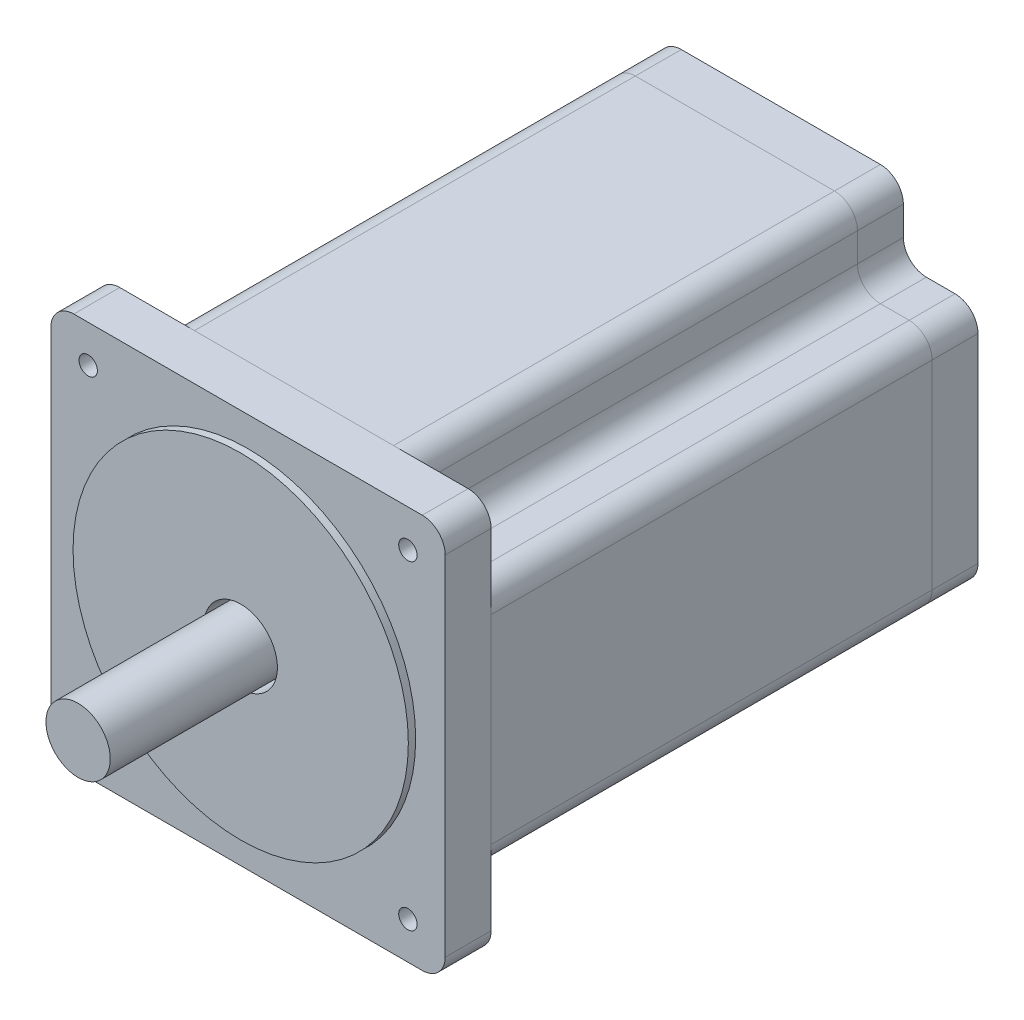
from build123d import *

# Parameters (mm, degrees)
SZKIC1_W                    = 85.85
SZKIC1_H                    = 85.85
DODANIE_WYCI_GNI_CIE2_DEPTH = 116
SZKIC3_R                    = 36.5
DODANIE_WYCI_GNI_CIE3_DEPTH = 1.6
SZKIC5_W                    = 16.25
SZKIC5_H                    = 16.25
WYTNIJ_WYCI_GNI_CIE1_DEPTH  = 106
SZYK_LINIOWY1_COUNT         = 2
SZYK_LINIOWY1_PITCH         = 69.6
SZYK_LINIOWY1_COUNT_DIR2    = 2
SZYK_LINIOWY1_PITCH_DIR2    = 69.6
SZKIC6_R                    = 2
WYTNIJ_WYCI_GNI_CIE2_DEPTH  = 10
SZYK_LINIOWY2_COUNT         = 2
SZYK_LINIOWY2_PITCH         = 69.6
SZYK_LINIOWY2_COUNT_DIR2    = 2
SZYK_LINIOWY2_PITCH_DIR2    = 69.6
SZKIC7_R                    = 7
DODANIE_WYCI_GNI_CIE4_DEPTH = 35.4
SZKIC8_R                    = 8
SZKIC8_R_2                  = 7
WYTNIJ_WYCI_GNI_CIE5_DEPTH  = 10
ZAOKR_GLENIE1_R             = 5
ZAOKR_GLENIE2_R             = 5
ZAOKR_GLENIE3_R             = 5


with BuildPart() as part:
    # Szkic1 → Dodanie-wyciągnięcie2 (new body)
    with BuildSketch(Plane.XY):
        Rectangle(SZKIC1_W, SZKIC1_H)
    extrude(amount=DODANIE_WYCI_GNI_CIE2_DEPTH)

    # Szkic3 → Dodanie-wyciągnięcie3 (add)
    with BuildSketch(Plane.XY.offset(116)):
        Circle(SZKIC3_R)
    extrude(amount=DODANIE_WYCI_GNI_CIE3_DEPTH)

    # Szkic5 → Wytnij-wyciągnięcie1 (cut)
    with BuildSketch(Plane(origin=(0, 0, 0), x_dir=(-1, 0, 0), z_dir=(0, 0, -1))):
        with Locations((-34.8, 34.8)):
            Rectangle(SZKIC5_W, SZKIC5_H)
    wytnij_wyci_gni_cie1 = extrude(amount=-WYTNIJ_WYCI_GNI_CIE1_DEPTH, mode=Mode.SUBTRACT)

    # Szyk liniowy1: Wytnij-wyci_gni_cie1 2 × 2
    with Locations(*[(-i * SZYK_LINIOWY1_PITCH, -j * SZYK_LINIOWY1_PITCH_DIR2, 0) for i in range(SZYK_LINIOWY1_COUNT) for j in range(SZYK_LINIOWY1_COUNT_DIR2) if (i, j) != (0, 0)]):
        add(wytnij_wyci_gni_cie1, mode=Mode.SUBTRACT)

    # Szkic6 → Wytnij-wyciągnięcie2 (cut)
    with BuildSketch(Plane.XY.offset(116)):
        with Locations((-34.8, 34.8)):
            Circle(SZKIC6_R)
    wytnij_wyci_gni_cie2 = extrude(amount=-WYTNIJ_WYCI_GNI_CIE2_DEPTH, mode=Mode.SUBTRACT)

    # Szyk liniowy2: Wytnij-wyci_gni_cie2 2 × 2
    with Locations(*[(i * SZYK_LINIOWY2_PITCH, -j * SZYK_LINIOWY2_PITCH_DIR2, 0) for i in range(SZYK_LINIOWY2_COUNT) for j in range(SZYK_LINIOWY2_COUNT_DIR2) if (i, j) != (0, 0)]):
        add(wytnij_wyci_gni_cie2, mode=Mode.SUBTRACT)

    # Szkic7 → Dodanie-wyciągnięcie4 (add)
    with BuildSketch(Plane.XY.offset(117.6)):
        Circle(SZKIC7_R)
    extrude(amount=DODANIE_WYCI_GNI_CIE4_DEPTH)

    # Szkic8 → Wytnij-wyciągnięcie5 (cut)
    with BuildSketch(Plane.XY.offset(117.6)):
        Circle(SZKIC8_R)
        Circle(SZKIC8_R_2, mode=Mode.SUBTRACT)
    extrude(amount=-WYTNIJ_WYCI_GNI_CIE5_DEPTH, mode=Mode.SUBTRACT)

    # Zaokrąglenie1
    zaokr_glenie1_edges = [part.edges().sort_by_distance(p)[0] for p in [
        (42.925, -42.925, 111),
        (-42.925, -42.925, 111),
        (-42.925, 42.925, 111),
        (42.925, 42.925, 111),
    ]]
    fillet(zaokr_glenie1_edges, radius=ZAOKR_GLENIE1_R)

    # Zaokrąglenie2
    zaokr_glenie2_edges = [part.edges().sort_by_distance(p)[0] for p in [
        (42.925, 26.675, 53),
        (26.675, 42.925, 53),
        (42.925, -26.675, 53),
        (26.675, -42.925, 53),
        (-26.675, 42.925, 53),
        (-42.925, 26.675, 53),
        (-26.675, -42.925, 53),
        (-42.925, -26.675, 53),
    ]]
    fillet(zaokr_glenie2_edges, radius=ZAOKR_GLENIE2_R)

    # Zaokrąglenie3
    zaokr_glenie3_edges = [part.edges().sort_by_distance(p)[0] for p in [
        (26.675, 26.675, 53),
        (26.675, -26.675, 53),
        (-26.675, 26.675, 53),
        (-26.675, -26.675, 53),
    ]]
    fillet(zaokr_glenie3_edges, radius=ZAOKR_GLENIE3_R)


solid = part.part
